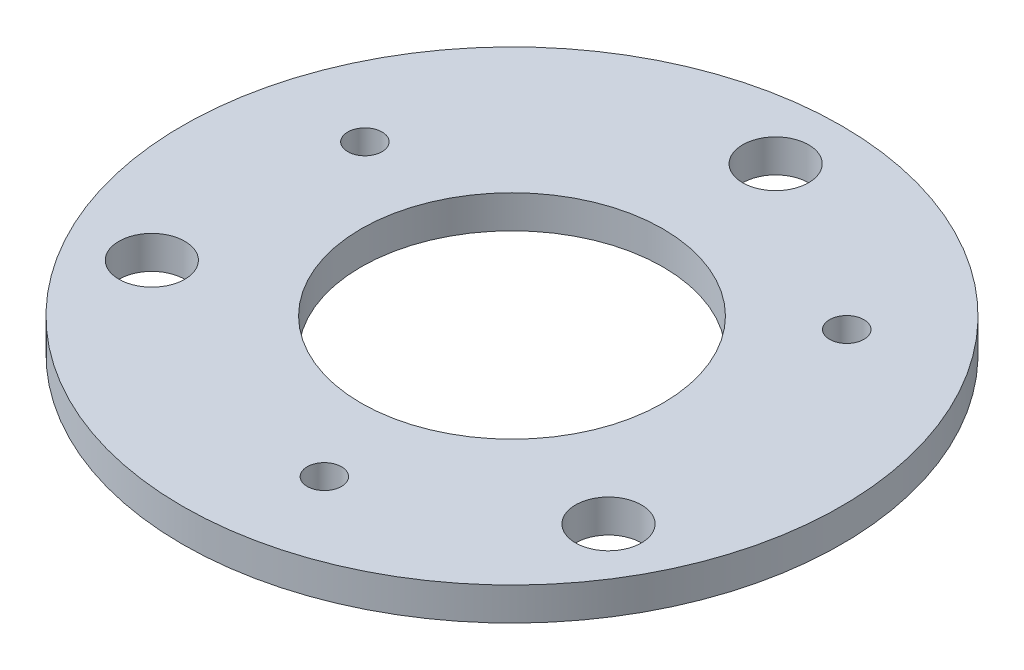
from build123d import *

# Parameters (mm, degrees)
SKETCH1_R           = 63.5
SKETCH1_R_2         = 29.083
SKETCH1_R_3         = 6.35
BOSS_EXTRUDE1_DEPTH = 6.35
SKETCH5_R           = 3.302
CUT_EXTRUDE4_DEPTH  = 7.35
CIRPATTERN2_COUNT   = 3


with BuildPart() as part:
    # Sketch1 → Boss-Extrude1 (new body)
    with BuildSketch(Plane(origin=(0, 0, 0), x_dir=(1, 0, 0), z_dir=(0, 1, 0))):
        Circle(SKETCH1_R)
        Circle(SKETCH1_R_2, mode=Mode.SUBTRACT)
        with Locations((0, 50.8)):
            Circle(SKETCH1_R_3, mode=Mode.SUBTRACT)
        with Locations((43.994090512, -25.4)):
            Circle(SKETCH1_R_3, mode=Mode.SUBTRACT)
        with Locations((-43.994090512, -25.4)):
            Circle(SKETCH1_R_3, mode=Mode.SUBTRACT)
    extrude(amount=BOSS_EXTRUDE1_DEPTH)

    # Sketch5 → Cut-Extrude4 (cut, through all)
    with BuildSketch(Plane(origin=(0, 6.35, 0), x_dir=(1, 0, 0), z_dir=(0, 1, 0))):
        with Locations((-43.229109276, 14.884976022)):
            Circle(SKETCH5_R)
    cut_extrude4 = extrude(amount=-CUT_EXTRUDE4_DEPTH, mode=Mode.SUBTRACT)

    # CirPattern2: Cut-Extrude4 ×3 about axis
    cirpattern2_axis = Axis((0, 0, 0), (0, 1, 0))
    for i in range(1, CIRPATTERN2_COUNT):
        add(cut_extrude4.rotate(cirpattern2_axis, i * 360 / CIRPATTERN2_COUNT), mode=Mode.SUBTRACT)


solid = part.part
